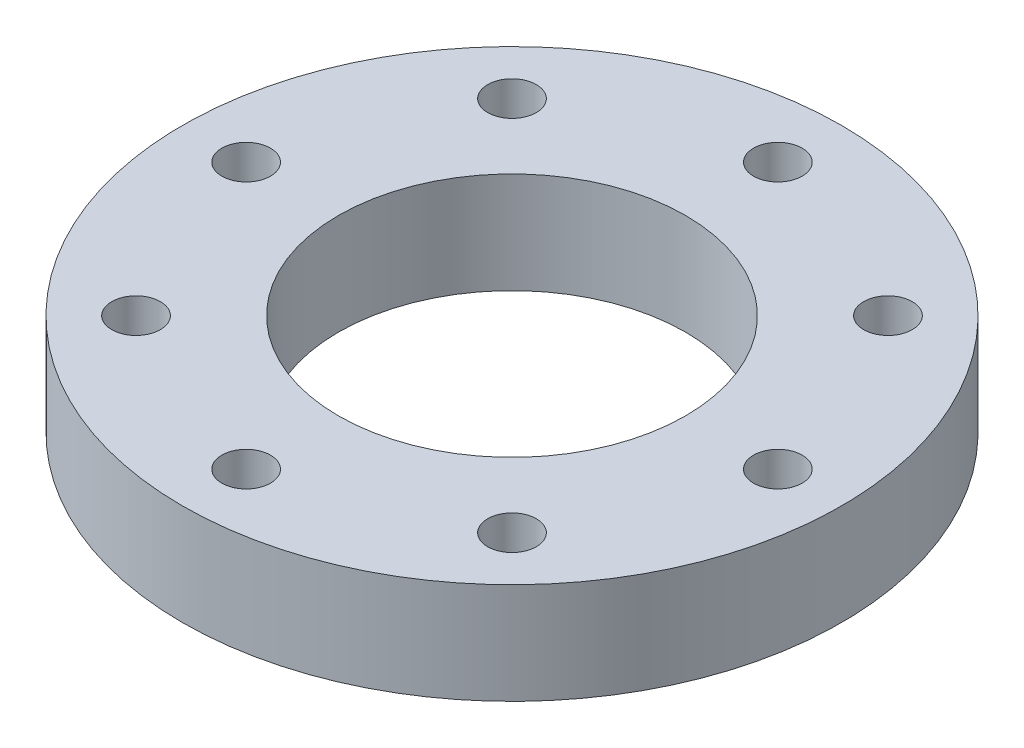
from build123d import *

# Parameters (mm, degrees)
SKETCH1_R           = 57.15
SKETCH1_R_2         = 30.099
EXTRUDE_THIN1_DEPTH = 17.526
SKETCH2_R           = 4.2164
CUT_EXTRUDE2_DEPTH  = 17.526
CIRPATTERN1_COUNT   = 8


with BuildPart() as part:
    # Sketch1 → Extrude-Thin1 (new body)
    with BuildSketch(Plane(origin=(0, 0, 0), x_dir=(1, 0, 0), z_dir=(0, 1, 0))):
        Circle(SKETCH1_R)
        Circle(SKETCH1_R_2, mode=Mode.SUBTRACT)
    extrude(amount=EXTRUDE_THIN1_DEPTH)

    # Sketch2 → Cut-Extrude2 (cut)
    with BuildSketch(Plane(origin=(0, 0, 0), x_dir=(1, 0, 0), z_dir=(0, 1, 0))):
        with Locations((0, 46.101)):
            Circle(SKETCH2_R)
    cut_extrude2 = extrude(amount=CUT_EXTRUDE2_DEPTH, mode=Mode.SUBTRACT)

    # CirPattern1: Cut-Extrude2 ×8 about axis
    cirpattern1_axis = Axis((0, 58.676993495, 0), (0, -1, 0))
    for i in range(1, CIRPATTERN1_COUNT):
        add(cut_extrude2.rotate(cirpattern1_axis, i * 360 / CIRPATTERN1_COUNT), mode=Mode.SUBTRACT)


solid = part.part
